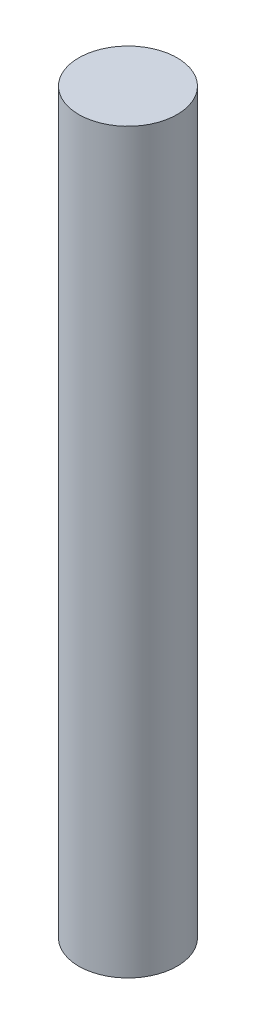
from build123d import *

# Parameters (mm, degrees)
SKETCH_1_R      = 2
EXTRUDE_1_DEPTH = 30


with BuildPart() as part:
    # Эскиз1 → Бобышка-Вытянуть1 (new body)
    with BuildSketch(Plane(origin=(0, 0, 0), x_dir=(1, 0, 0), z_dir=(0, 1, 0))):
        Circle(SKETCH_1_R)
    extrude(amount=EXTRUDE_1_DEPTH)


solid = part.part
